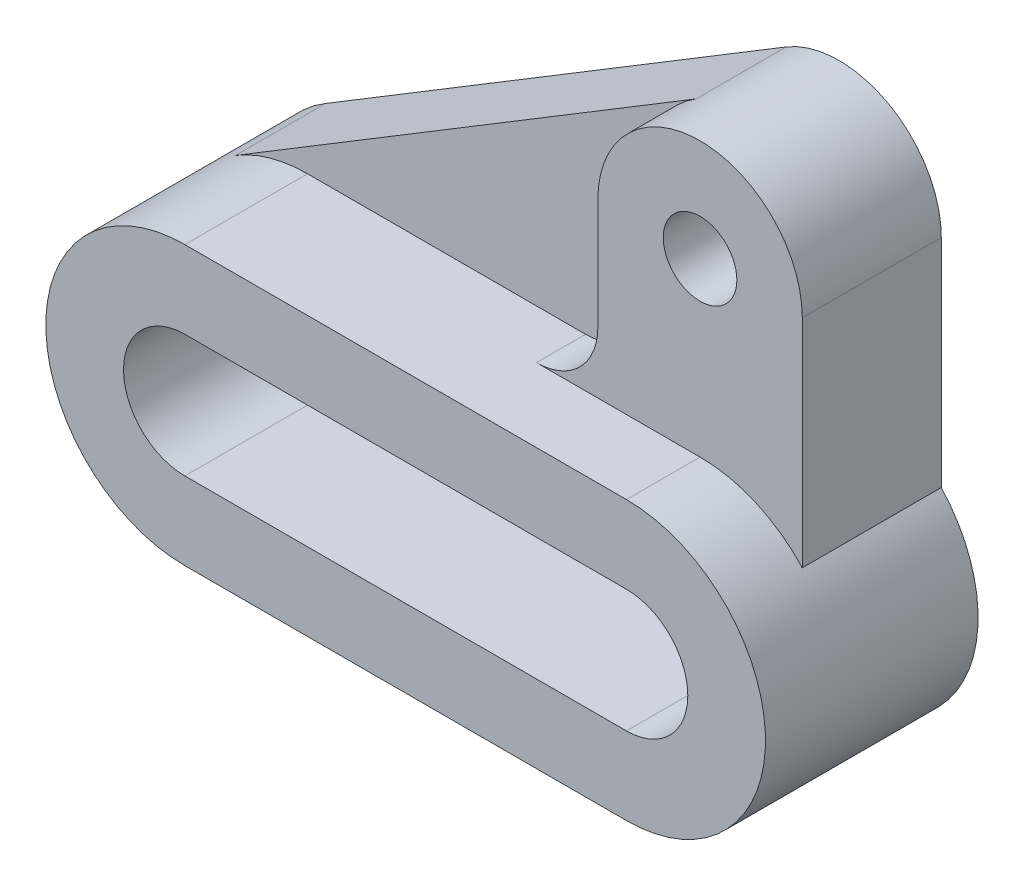
from build123d import *

# Parameters (mm, degrees)
BOSS_EXTRUDE1_DEPTH = 52
BOSS_EXTRUDE2_DEPTH = 22
SKETCH1_6_R         = 9
BOSS_EXTRUDE3_DEPTH = 34
FILLET1_R           = 15


with BuildPart() as part:
    # Sketch1 → Boss-Extrude1 (new body)
    with BuildSketch(Plane.XY):
        with BuildLine():
            Line((83, 34), (0, 34))
            ThreePointArc((0, 34), (-9.150825608, 32.745417858), (-17.626329898, 29.074258276))
            ThreePointArc((-17.626329898, 29.074258276), (-32.745417858, -9.150825608), (0, -34))
            Line((0, -34), (108, -34))
            ThreePointArc((108, -34), (139.140623519, -13.647767834), (133, 23.043437244))
            ThreePointArc((133, 23.043437244), (121.647767834, 31.140623519), (108, 34))
            Line((108, 34), (83, 34))
        make_face()
        with BuildLine():
            ThreePointArc((0, -15), (-15, 0), (0, 15))
            Line((0, 15), (108, 15))
            ThreePointArc((108, 15), (123, 0), (108, -15))
            Line((108, -15), (0, -15))
        make_face(mode=Mode.SUBTRACT)
    extrude(amount=BOSS_EXTRUDE1_DEPTH)

    # Sketch1_5 → Boss-Extrude2 (add)
    with BuildSketch(Plane.XY):
        with BuildLine():
            ThreePointArc((-17.626329898, 29.074258276), (-9.150825608, 32.745417858), (0, 34))
            Line((0, 34), (83, 34))
            Line((83, 34), (83, 76))
            ThreePointArc((83, 76), (86.216825102, 88.26757072), (95.03946331, 97.378131086))
            Line((95.03946331, 97.378131086), (-17.626329898, 29.074258276))
        make_face()
    extrude(amount=BOSS_EXTRUDE2_DEPTH)

    # Sketch1_6 → Boss-Extrude3 (add)
    with BuildSketch(Plane.XY):
        with BuildLine():
            Line((83, 76), (83, 34))
            Line((83, 34), (108, 34))
            ThreePointArc((108, 34), (121.647767834, 31.140623519), (133, 23.043437244))
            Line((133, 23.043437244), (133, 76))
            ThreePointArc((133, 76), (120.26757072, 97.783174898), (95.03946331, 97.378131086))
            ThreePointArc((95.03946331, 97.378131086), (86.216825102, 88.26757072), (83, 76))
        make_face()
        with Locations((108, 76)):
            Circle(SKETCH1_6_R, mode=Mode.SUBTRACT)
    extrude(amount=BOSS_EXTRUDE3_DEPTH)

    # Fillet1
    fillet1_edges = [part.edges().sort_by_distance(p)[0] for p in [
        (83, 34, 28),
    ]]
    fillet(fillet1_edges, radius=FILLET1_R)


solid = part.part
